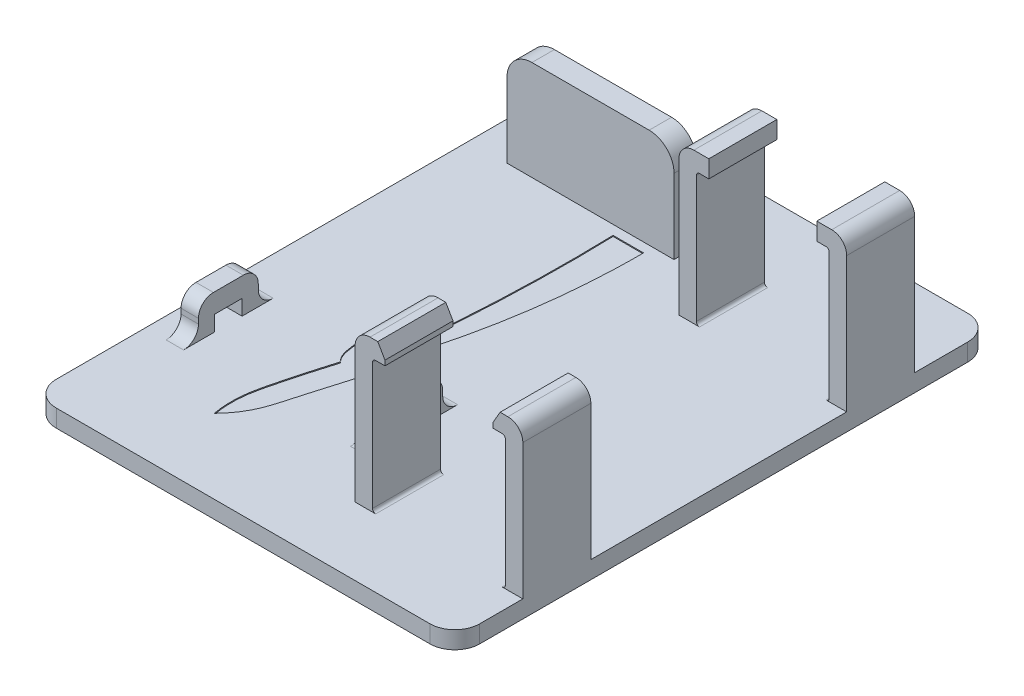
from build123d import *

# Parameters (mm, degrees)
BOSS_EXTRUDE1_DEPTH    = 3.5
SKETCH2_W              = 3.5
SKETCH2_H              = 13.652749
BOSS_EXTRUDE2_DEPTH    = 26.67
SKETCH3_W              = 6
SKETCH3_H              = 13.652749
BOSS_EXTRUDE3_DEPTH    = 3.5
CHAMFER1_SIZE          = 2.5
CHAMFER1_SIZE2         = 1.443375673
CHAMFER1_PART_2_SIZE   = 2.5
CHAMFER1_PART_2_SIZE2  = 1.443375673
FILLET1_R              = 3
FILLET2_R              = 0.635
LPATTERN1_COUNT        = 2
LPATTERN1_PITCH        = 65
FILLET1_OF_LPATTERN1_R = 3
FILLET2_OF_LPATTERN1_R = 0.635
SKETCH4_W              = 33.518366389
SKETCH4_H              = 4.5
BOSS_EXTRUDE4_DEPTH    = 20
FILLET3_R              = 3
FILLET4_R              = 5
CUT_EXTRUDE1_DEPTH     = 0.2
SKETCH6_W              = 3.5
SKETCH6_H              = 12
BOSS_EXTRUDE5_DEPTH    = 7
FILLET5_R              = 3
SKETCH7_W              = 5.5
SKETCH7_H              = 3.093997842
CUT_EXTRUDE2_DEPTH     = 45.698420621


with BuildPart() as part:
    # Sketch1 → Boss-Extrude1 (new body)
    with BuildSketch(Plane(origin=(0, 0, 0), x_dir=(1, 0, 0), z_dir=(0, 1, 0))):
        with BuildLine():
            Line((-40.496062992, 57.25839895), (34.503937008, 57.25839895))
            ThreePointArc((34.503937008, 57.25839895), (38.039470914, 55.793932856), (39.503937008, 52.25839895))
            Line((39.503937008, 52.25839895), (39.503937008, -45.69160105))
            ThreePointArc((39.503937008, -45.69160105), (38.039470914, -49.227134956), (34.503937008, -50.69160105))
            Line((34.503937008, -50.69160105), (-40.496062992, -50.69160105))
            ThreePointArc((-40.496062992, -50.69160105), (-44.031596898, -49.227134956), (-45.496062992, -45.69160105))
            Line((-45.496062992, -45.69160105), (-45.496062992, 52.25839895))
            ThreePointArc((-45.496062992, 52.25839895), (-44.031596898, 55.793932856), (-40.496062992, 57.25839895))
        make_face()
    extrude(amount=BOSS_EXTRUDE1_DEPTH)

    # Sketch2 → Boss-Extrude2 (add)
    with BuildSketch(Plane(origin=(0, 3.5, 0), x_dir=(1, 0, 0), z_dir=(0, 1, 0))):
        with Locations((37.753937008, -30.2164939)):
            Rectangle(SKETCH2_W, SKETCH2_H)
        with Locations((7.583937008, -30.2164939)):
            Rectangle(SKETCH2_W, SKETCH2_H)
    boss_extrude2 = extrude(amount=BOSS_EXTRUDE2_DEPTH)

    # Sketch3 → Boss-Extrude3 (add)
    with BuildSketch(Plane(origin=(0, 30.17, 0), x_dir=(1, 0, 0), z_dir=(0, 1, 0))):
        with Locations((8.833937008, -30.2164939)):
            Rectangle(SKETCH3_W, SKETCH3_H)
        with Locations((36.503937008, -30.2164939)):
            Rectangle(SKETCH3_W, SKETCH3_H)
    boss_extrude3 = extrude(amount=BOSS_EXTRUDE3_DEPTH)

    # Chamfer1
    chamfer1_edges = [part.edges().sort_by_distance(p)[0] for p in [
        (11.833937008, 33.67, 30.2164939),
    ]]
    chamfer1_side = [part.faces().sort_by_distance(p)[0] for p in [
        (11.833937008, 31.92, 30.2164939),
    ]]
    chamfer(chamfer1_edges, length=CHAMFER1_SIZE, length2=CHAMFER1_SIZE2, reference=chamfer1_side[0])

    # Chamfer1 part 2
    chamfer1_part_2_edges = [part.edges().sort_by_distance(p)[0] for p in [
        (33.503937008, 33.67, 30.2164939),
    ]]
    chamfer1_part_2_side = [part.faces().sort_by_distance(p)[0] for p in [
        (33.503937008, 31.92, 30.2164939),
    ]]
    chamfer(chamfer1_part_2_edges, length=CHAMFER1_PART_2_SIZE, length2=CHAMFER1_PART_2_SIZE2, reference=chamfer1_part_2_side[0])

    # Fillet1
    fillet1_edges = [part.edges().sort_by_distance(p)[0] for p in [
        (5.833937008, 33.67, 30.2164939),
        (39.503937008, 33.67, 30.2164939),
    ]]
    fillet(fillet1_edges, radius=FILLET1_R)

    # Fillet2
    fillet2_edges = [part.edges().sort_by_distance(p)[0] for p in [
        (36.003937008, 3.5, 30.2164939),
        (36.003937008, 30.17, 30.2164939),
        (9.333937008, 3.5, 30.2164939),
        (9.333937008, 30.17, 30.2164939),
    ]]
    fillet(fillet2_edges, radius=FILLET2_R)

    # LPattern1: Boss-Extrude2, Boss-Extrude3 ×2
    with Locations(*[(0, 0, -i * LPATTERN1_PITCH) for i in range(1, LPATTERN1_COUNT)]):
        add(boss_extrude2)
        add(boss_extrude3)

    # Fillet1 of LPattern1
    fillet1_of_lpattern1_edges = [part.edges().sort_by_distance(p)[0] for p in [
        (5.833937008, 33.67, -34.7835061),
        (39.503937008, 33.67, -34.7835061),
    ]]
    fillet(fillet1_of_lpattern1_edges, radius=FILLET1_OF_LPATTERN1_R)

    # Fillet2 of LPattern1
    fillet2_of_lpattern1_edges = [part.edges().sort_by_distance(p)[0] for p in [
        (36.003937008, 3.5, -34.7835061),
        (36.003937008, 30.17, -34.7835061),
        (9.333937008, 3.5, -34.7835061),
        (9.333937008, 30.17, -34.7835061),
    ]]
    fillet(fillet2_of_lpattern1_edges, radius=FILLET2_OF_LPATTERN1_R)

    # Sketch4 → Boss-Extrude4 (add)
    with BuildSketch(Plane(origin=(0, 3.5, 0), x_dir=(1, 0, 0), z_dir=(0, 1, 0))):
        with Locations((-21.056825666, 39.3598806)):
            Rectangle(SKETCH4_W, SKETCH4_H)
    extrude(amount=BOSS_EXTRUDE4_DEPTH)

    # Fillet3
    fillet3_edges = [part.edges().sort_by_distance(p)[0] for p in [
        (-21.056825666, 3.5, -41.6098806),
    ]]
    fillet(fillet3_edges, radius=FILLET3_R)

    # Fillet4
    fillet4_edges = [part.edges().sort_by_distance(p)[0] for p in [
        (-37.81600886, 23.5, -39.3598806),
        (-4.297642471, 23.5, -39.3598806),
    ]]
    fillet(fillet4_edges, radius=FILLET4_R)

    # Sketch5 → Cut-Extrude1 (cut)
    with BuildSketch(Plane(origin=(0, 3.5, 0), x_dir=(1, 0, 0), z_dir=(0, 1, 0))):
        with BuildLine():
            Line((-15.281743896, -10.888246155), (-14.625493896, -8.281996155))
            Line((-14.625493896, -8.281996155), (-17.025493896, -7.578871155))
            Line((-17.025493896, -7.578871155), (-17.700493896, -10.147621155))
            add(Edge.make_bspline(
                [(-17.700493896, -10.147621155), (-19.396549499, -9.080578613), (-20.737591063, -7.533973694), (-21.553618896, -5.703871155)],
                knots=[13, 13, 13, 13, 14, 14, 14, 14], degree=3))
            add(Edge.make_bspline(
                [(-21.553618896, -5.703871155), (-21.70328015, -7.197338867), (-21.696999633, -8.702333069), (-21.534868896, -10.194496155)],
                knots=[14, 14, 14, 14, 15, 15, 15, 15], degree=3))
            add(Edge.make_bspline(
                [(-21.534868896, -10.194496155), (-21.315494811, -12.189494324), (-20.911994445, -13.211369324), (-20.156743896, -13.963246155)],
                knots=[15, 15, 15, 15, 16, 16, 16, 16], degree=3))
            add(Edge.make_bspline(
                [(-20.156743896, -13.963246155), (-20.091869628, -14.027745056), (-20.035994994, -14.078749084), (-19.997368896, -14.113246155)],
                knots=[16, 16, 16, 16, 17, 17, 17, 17], degree=3))
            add(Edge.make_bspline(
                [(-19.997368896, -14.113246155), (-20.897368896, -17.103871155), (-21.657119262, -19.806123352), (-22.287867248, -22.153993225)],
                knots=[17, 17, 17, 17, 18, 18, 18, 18], degree=3))
            add(Edge.make_bspline(
                [(-22.287867248, -22.153993225), (-23.700493896, -27.408122253), (-24.180871093, -29.814118957), (-24.037993896, -32.853871155)],
                knots=[18, 18, 18, 18, 19, 19, 19, 19], degree=3))
            add(Edge.make_bspline(
                [(-24.037993896, -32.853871155), (-23.992158019, -33.828010559), (-23.885956847, -34.798377991), (-23.719994628, -35.759370422)],
                knots=[0, 0, 0, 0, 1, 1, 1, 1], degree=3))
            add(Edge.make_bspline(
                [(-23.719994628, -35.759370422), (-22.883967101, -34.893428039), (-22.128826415, -33.952888489), (-21.463993346, -32.949497986)],
                knots=[1, 1, 1, 1, 2, 2, 2, 2], degree=3))
            add(Edge.make_bspline(
                [(-21.463993346, -32.949497986), (-19.566118896, -30.082995605), (-19.168619811, -27.699497986), (-17.737993896, -22.803871155)],
                knots=[2, 2, 2, 2, 3, 3, 3, 3], degree=3))
            add(Edge.make_bspline(
                [(-17.737993896, -22.803871155), (-17.368619811, -21.540873718), (-16.61037091, -18.950746155), (-15.553618896, -15.378871155)],
                knots=[3, 3, 3, 3, 4, 4, 4, 4], degree=3))
            add(Edge.make_bspline(
                [(-15.553618896, -15.378871155), (-15.389391601, -15.359114075), (-15.226574218, -15.329057312), (-15.066118896, -15.288870239)],
                knots=[4, 4, 4, 4, 5, 5, 5, 5], degree=3))
            add(Edge.make_bspline(
                [(-15.066118896, -15.288870239), (-13.929491698, -15.004621887), (-13.060244262, -14.24299469), (-11.335619628, -11.938246155)],
                knots=[5, 5, 5, 5, 6, 6, 6, 6], degree=3))
            add(Edge.make_bspline(
                [(-11.335619628, -11.938246155), (-10.826746642, -11.258370972), (-10.197495543, -10.381996155), (-9.507494628, -9.331996155)],
                knots=[6, 6, 6, 6, 7, 7, 7, 7], degree=3))
            add(Edge.make_bspline(
                [(-9.507494628, -9.331996155), (-10.174946105, -9.671437073), (-10.860044372, -9.974989319), (-11.559868896, -10.241371155)],
                knots=[7, 7, 7, 7, 8, 8, 8, 8], degree=3))
            add(Edge.make_bspline(
                [(-11.559868896, -10.241371155), (-13.16974591, -10.853373718), (-13.924991881, -10.911120605), (-14.212993896, -10.925746155)],
                knots=[8, 8, 8, 8, 9, 9, 9, 9], degree=3))
            add(Edge.make_bspline(
                [(-14.212993896, -10.925746155), (-14.56966046, -10.943598938), (-14.927205932, -10.931056213), (-15.281743896, -10.888246155)],
                knots=[9, 9, 9, 9, 10, 10, 10, 10], degree=3))
        make_face()
        with BuildLine():
            Line((-8.52611798, 35.211631775), (-14.637867248, 35.211256409))
            add(Edge.make_bspline(
                [(-14.637867248, 35.211256409), (-14.433118712, 28.103129578), (-14.466869628, 20.481254578), (-14.850493896, 12.408253479)],
                knots=[1, 1, 1, 1, 2, 2, 2, 2], degree=3))
            add(Edge.make_bspline(
                [(-14.850493896, 12.408253479), (-15.187618529, 5.313250733), (-15.760244262, -1.404124451), (-16.488120543, -7.704124451)],
                knots=[2, 2, 2, 2, 3, 3, 3, 3], degree=3))
            Line((-16.488120543, -7.704124451), (-15.037993896, -8.128997803))
            add(Edge.make_bspline(
                [(-15.037993896, -8.128997803), (-10.656778991, 5.898258972), (-8.460442626, 20.516236878), (-8.52611798, 35.211631775)],
                knots=[4, 4, 4, 4, 5, 5, 5, 5], degree=3))
        make_face()
    extrude(amount=-CUT_EXTRUDE1_DEPTH, mode=Mode.SUBTRACT)

    # Sketch6 → Boss-Extrude5 (add)
    with BuildSketch(Plane(origin=(0, 3.5, 0), x_dir=(1, 0, 0), z_dir=(0, 1, 0))):
        with Locations((-2.547642471, -18.825406041)):
            Rectangle(SKETCH6_W, SKETCH6_H)
        with Locations((-39.56600886, -18.825406041)):
            Rectangle(SKETCH6_W, SKETCH6_H)
    extrude(amount=BOSS_EXTRUDE5_DEPTH)

    # Fillet5
    fillet5_edges = [part.edges().sort_by_distance(p)[0] for p in [
        (-2.547642471, 3.5, 24.825406041),
        (-2.547642471, 3.5, 12.825406041),
        (-2.547642471, 10.5, 24.825406041),
        (-2.547642471, 10.5, 12.825406041),
        (-39.56600886, 3.5, 24.825406041),
        (-39.56600886, 3.5, 12.825406041),
        (-39.56600886, 10.5, 24.825406041),
        (-39.56600886, 10.5, 12.825406041),
    ]]
    fillet(fillet5_edges, radius=FILLET5_R)

    # Sketch7 → Cut-Extrude2 (cut, through all)
    with BuildSketch(Plane(origin=(-0.797642471, 0, 0), x_dir=(0, 0, -1), z_dir=(1, 0, 0))):
        with Locations((-18.825406041, 5.046998921)):
            Rectangle(SKETCH7_W, SKETCH7_H)
    extrude(amount=-CUT_EXTRUDE2_DEPTH, mode=Mode.SUBTRACT)


solid = part.part
